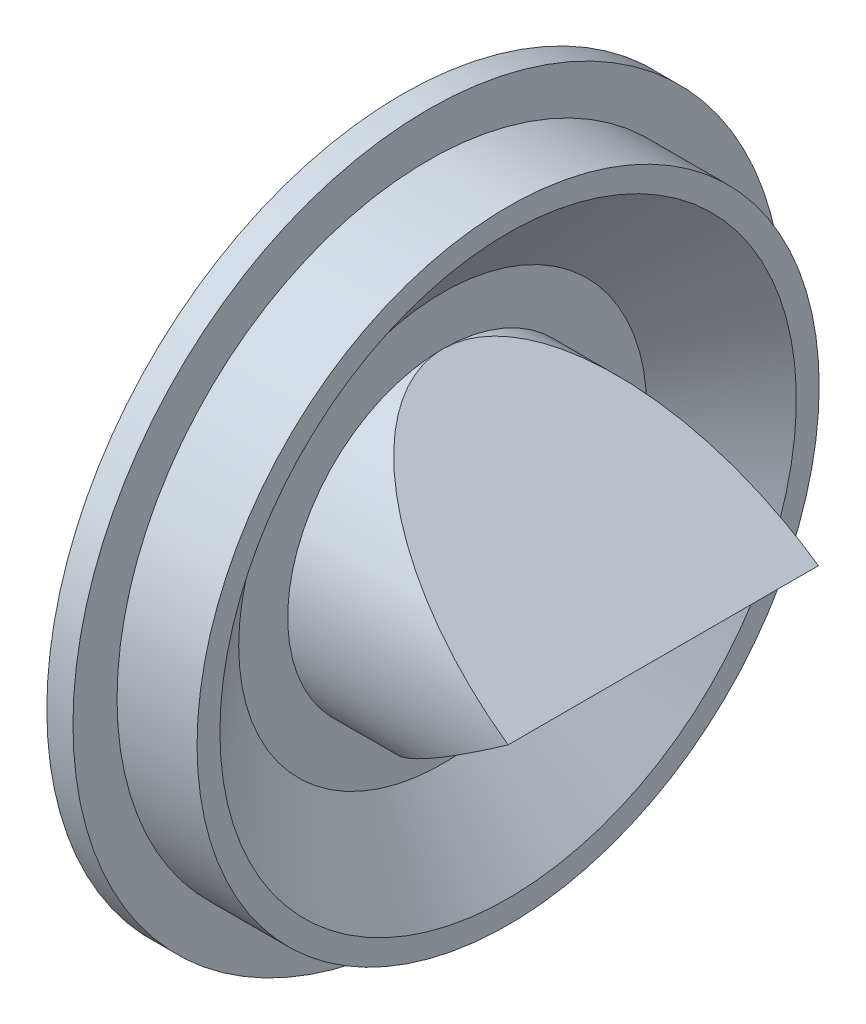
from build123d import *
from build123d.topology import SkipClean

# Parameters (mm, degrees)
SKETCH3_R               = 9.5
BOSS_EXTRUDE1_DEPTH     = 16
CUT_EXTRUDE1_DEPTH      = 21.892582416
CUT_EXTRUDE1_DEPTH_BACK = 21.892582416
SHELL7_T                = -0.3
SKETCH8_R               = 10.705762979
CUT_EXTRUDE5_DEPTH      = 10


with BuildPart() as part:
    # Sketch3 → Boss-Extrude1 (new body)
    with BuildSketch(Plane.ZY):
        Circle(SKETCH3_R)
    extrude(amount=-BOSS_EXTRUDE1_DEPTH)

    # Sketch4 → Cut-Extrude1 (cut, two sides: drawn at the far end of the back side and taken through both)
    with BuildSketch(Plane.XY.offset(-CUT_EXTRUDE1_DEPTH_BACK)):
        Polygon((2.5, 9.5), (18.05891099, 17.267926144), (18.05891099, -17.267926144), (2.5, -9.5), (16, 0), align=None)
    extrude(amount=CUT_EXTRUDE1_DEPTH + CUT_EXTRUDE1_DEPTH_BACK, mode=Mode.SUBTRACT)

    # Shell7
    shell7_openings = [part.faces().sort_by_distance(p)[0] for p in [
        (0, 0, 0),
    ]]
    offset(amount=SHELL7_T, openings=shell7_openings, kind=Kind.INTERSECTION)

    # Sketch1 → Revolve1 (revolve)
    with SkipClean():  # the faces are left unmerged after this step: merging them gives an invalid solid
        with BuildSketch(Plane.XY, mode=Mode.PRIVATE) as revolve1_sk:
            Polygon((0, 18.75), (0, 21.75), (1.6, 21.75), (1.6, 19.05), (6.5, 19.05), (6.5, 17.65), (2.5, 12.5), (2.5, 9.5), (2.2, 9.5), (2.2, 12.602819589), (6.2, 17.752819589), (6.2, 18.75), align=None)
        revolve(revolve1_sk.sketch.rotate(Axis((0, 0, 0), (1, 0, 0)), 90), axis=Axis((0, 0, 0), (1, 0, 0)))

    # Sketch8 → Cut-Extrude5 (cut)
    with SkipClean():  # the faces are left unmerged after this step: merging them gives an invalid solid
        with BuildSketch(Plane.ZY.offset(-2.2)):
            Circle(SKETCH8_R)
        extrude(amount=CUT_EXTRUDE5_DEPTH, mode=Mode.SUBTRACT)


solid = part.part
